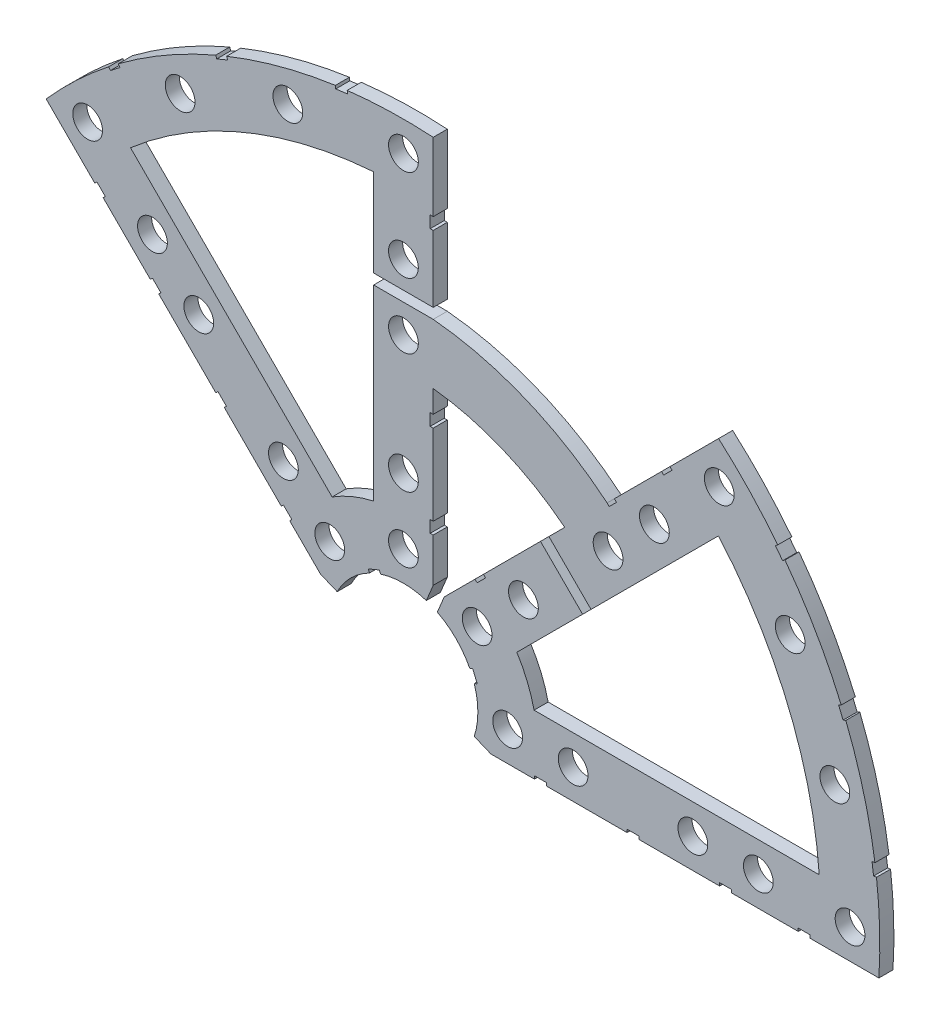
from build123d import *

# Parameters (mm, degrees)
BOSS_EXTRUDE1_DEPTH = 3.000000096
SKETCH2_R           = 3.175
CUT_EXTRUDE1_DEPTH  = 4.000000096
SKETCH3_W           = 2.54
SKETCH3_H           = 0.635
SKETCH3_W_2         = 12.7
SKETCH3_H_2         = 2.201822509
SKETCH3_W_3         = 0.635
SKETCH3_H_3         = 2.54
CUT_EXTRUDE2_DEPTH  = 4.000000096


with BuildPart() as part:
    # Sketch1 → Boss-Extrude1 (new body)
    with BuildSketch(Plane.XY):
        with BuildLine():
            Line((8.696654013, 17.676910134), (34.405475059, 43.38573118))
            ThreePointArc((34.405475059, 43.38573118), (21.189947017, 51.157057474), (6.35, 55.006689448))
            Line((6.35, 55.006689448), (6.35, 18.648926052))
            Line((6.35, 18.648926052), (4.88230096, 15.105587123))
            ThreePointArc((4.88230096, 15.105587123), (-6.075099489, 14.666587579), (-14.133571205, 7.228954972))
            Line((-14.133571205, 7.228954972), (-17.676910134, 8.696654013))
            Line((-17.676910134, 8.696654013), (-76.191723231, 67.21146711))
            ThreePointArc((-76.191723231, 67.21146711), (-38.880636728, 93.866160503), (6.35, 101.401368334))
            Line((6.35, 101.401368334), (6.35, 67.775177491))
            ThreePointArc((6.35, 67.775177491), (26.050026608, 62.890327537), (43.43415954, 52.414415661))
            Line((43.43415954, 52.414415661), (67.21146711, 76.191723231))
            ThreePointArc((67.21146711, 76.191723231), (93.866160503, 38.880636728), (101.401368334, -6.35))
            Line((101.401368334, -6.35), (18.648926052, -6.35))
            Line((18.648926052, -6.35), (15.105587123, -4.88230096))
            ThreePointArc((15.105587123, -4.88230096), (14.666587579, 6.075099489), (7.228954972, 14.133571205))
            Line((7.228954972, 14.133571205), (8.696654013, 17.676910134))
        make_face()
        with BuildLine():
            Line((88.672924278, 6.35), (27.86051193, 6.35))
            ThreePointArc((27.86051193, 6.35), (26.399857642, 10.93517908), (24.190484974, 15.210228852))
            Line((24.190484974, 15.210228852), (67.191354125, 58.211098004))
            ThreePointArc((67.191354125, 58.211098004), (82.13289044, 34.020557137), (88.672924278, 6.35))
        make_face(mode=Mode.SUBTRACT)
        with BuildLine():
            Line((-58.211098004, 67.191354125), (-15.210228852, 24.190484974))
            ThreePointArc((-15.210228852, 24.190484974), (-10.93517908, 26.399857642), (-6.35, 27.86051193))
            Line((-6.35, 27.86051193), (-6.35, 88.672924278))
            ThreePointArc((-6.35, 88.672924278), (-34.020557137, 82.13289044), (-58.211098004, 67.191354125))
        make_face(mode=Mode.SUBTRACT)
    extrude(amount=BOSS_EXTRUDE1_DEPTH)

    # Sketch2 → Cut-Extrude1 (cut, through all)
    with BuildSketch(Plane.XY.offset(3.000000096)):
        with Locations((22.225, 0)):
            Circle(SKETCH2_R)
        with Locations((36.195, 0)):
            Circle(SKETCH2_R)
        with Locations((61.722, 0)):
            Circle(SKETCH2_R)
        with Locations((75.692, 0)):
            Circle(SKETCH2_R)
        with Locations((95.25, 0)):
            Circle(SKETCH2_R)
        with Locations((15.715448212, 15.715448212)):
            Circle(SKETCH2_R)
        with Locations((25.593729945, 25.593729945)):
            Circle(SKETCH2_R)
        with Locations((43.644044748, 43.644044748)):
            Circle(SKETCH2_R)
        with Locations((53.522326482, 53.522326482)):
            Circle(SKETCH2_R)
        with Locations((92.004434954, 24.652514046)):
            Circle(SKETCH2_R)
        with Locations((82.48891971, 47.625)):
            Circle(SKETCH2_R)
        with Locations((67.351920908, 67.351920908)):
            Circle(SKETCH2_R)
        with Locations((0, 95.25)):
            Circle(SKETCH2_R)
        with Locations((0, 75.692)):
            Circle(SKETCH2_R)
        with Locations((-53.522326482, 53.522326482)):
            Circle(SKETCH2_R)
        with Locations((-43.644044748, 43.644044748)):
            Circle(SKETCH2_R)
        with Locations((0, 61.722)):
            Circle(SKETCH2_R)
        with Locations((0, 36.195)):
            Circle(SKETCH2_R)
        with Locations((-25.593729945, 25.593729945)):
            Circle(SKETCH2_R)
        with Locations((-15.715448212, 15.715448212)):
            Circle(SKETCH2_R)
        with Locations((0, 22.225)):
            Circle(SKETCH2_R)
        with Locations((-24.652514046, 92.004434954)):
            Circle(SKETCH2_R)
        with Locations((-47.625, 82.48891971)):
            Circle(SKETCH2_R)
        with Locations((-67.351920908, 67.351920908)):
            Circle(SKETCH2_R)
    extrude(amount=-CUT_EXTRUDE1_DEPTH, mode=Mode.SUBTRACT)

    # Sketch3 → Cut-Extrude2 (cut, through all)
    with BuildSketch(Plane.XY.offset(3.000000096)):
        Polygon((15.266435406, 24.246691527), (17.06248663, 26.042742751), (17.511499436, 25.593729945), (15.715448212, 23.797678721), align=None)
        Polygon((55.048970022, 64.029226143), (56.845021246, 65.825277367), (57.294034052, 65.376264561), (55.497982828, 63.580213337), align=None)
        Polygon((29.230733674, 38.210989795), (31.026784898, 40.007041019), (40.007041019, 31.026784898), (38.210989795, 29.230733674), align=None)
        with Locations((29.21, -6.0325)):
            Rectangle(SKETCH3_W, SKETCH3_H)
        with Locations((68.707, -6.0325)):
            Rectangle(SKETCH3_W, SKETCH3_H)
        Polygon((43.43415954, 52.414415661), (44.991083167, 53.971339288), (45.440095973, 53.522326482), (43.883172346, 51.965402855), align=None)
        with Locations((48.9585, -6.0325)):
            Rectangle(SKETCH3_W, SKETCH3_H)
        with Locations((85.471, -6.0325)):
            Rectangle(SKETCH3_W, SKETCH3_H)
        Polygon((99.935462164, 14.437711971), (100.266998693, 11.919442024), (101.526133667, 12.085210288), (101.194597138, 14.603480236), align=None)
        Polygon((93.765504959, 37.464305742), (94.938831965, 37.950313702), (93.966816047, 40.296967714), (92.793489041, 39.810959755), align=None)
        Polygon((79.327792988, 62.471156422), (80.874047017, 60.456038938), (81.88160576, 61.229165953), (80.33535173, 63.244283437), align=None)
        Polygon((13.593916116, 7.005422516), (14.565932035, 4.658768503), (15.739259041, 5.144776462), (14.767243123, 7.491430475), align=None)
        with Locations((0, 68.876088745)):
            Rectangle(SKETCH3_W_2, SKETCH3_H_2)
        Polygon((-40.007041019, 31.026784898), (-38.210989795, 29.230733674), (-37.761976989, 29.67974648), (-39.558028213, 31.475797704), align=None)
        Polygon((-26.042742751, 17.06248663), (-25.593729945, 17.511499436), (-23.797678721, 15.715448212), (-24.246691527, 15.266435406), align=None)
        Polygon((-65.825277367, 56.845021246), (-64.029226143, 55.048970022), (-63.580213337, 55.497982828), (-65.376264561, 57.294034052), align=None)
        Polygon((-63.244283437, 80.33535173), (-61.229165953, 81.88160576), (-60.456038938, 80.874047017), (-62.471156422, 79.327792988), align=None)
        Polygon((-37.950313702, 94.938831965), (-40.296967714, 93.966816047), (-39.810959755, 92.793489041), (-37.464305742, 93.765504959), align=None)
        Polygon((-14.437711971, 99.935462165), (-14.603480236, 101.194597138), (-12.085210288, 101.526133667), (-11.919442024, 100.266998693), align=None)
        with Locations((6.0325, 85.471)):
            Rectangle(SKETCH3_W_3, SKETCH3_H_3)
        with Locations((6.0325, 48.9585)):
            Rectangle(SKETCH3_W_3, SKETCH3_H_3)
        with Locations((6.0325, 29.21)):
            Rectangle(SKETCH3_W_3, SKETCH3_H_3)
        Polygon((-7.491430475, 14.767243123), (-5.144776462, 15.739259041), (-4.658768503, 14.565932035), (-7.005422516, 13.593916116), align=None)
        Polygon((-53.971339288, 44.991083167), (-52.175288063, 43.195031942), (-51.726275257, 43.644044748), (-53.522326482, 45.440095973), align=None)
    extrude(amount=-CUT_EXTRUDE2_DEPTH, mode=Mode.SUBTRACT)


solid = part.part
